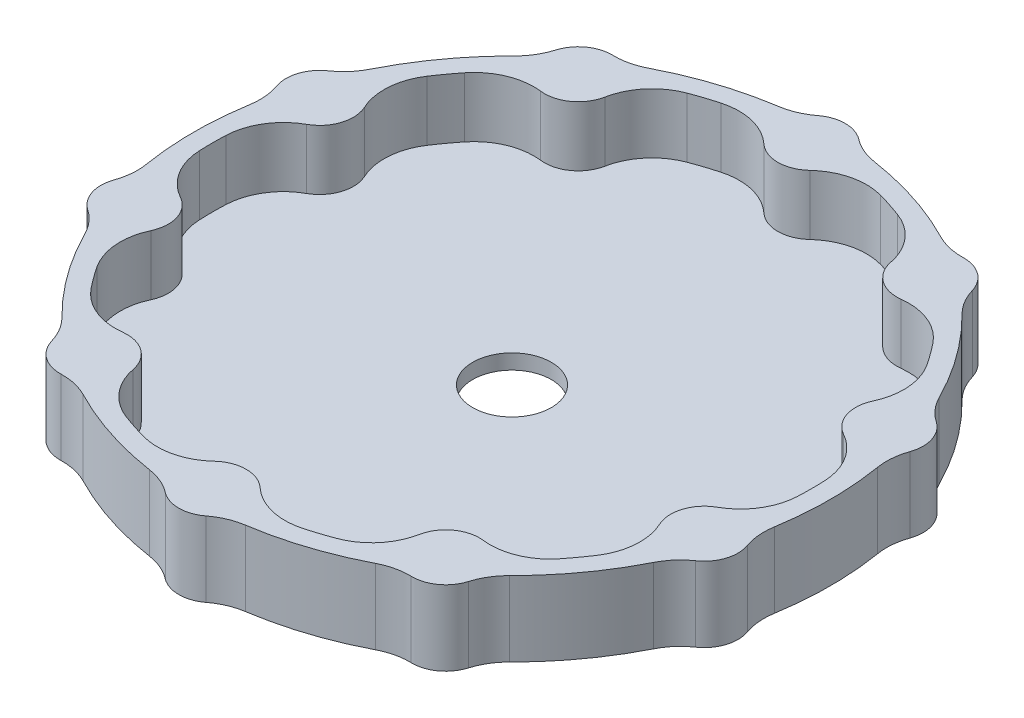
from build123d import *

# Parameters (mm, degrees)
SKETCH1_R                = 42.5
BOSS_EXTRUDE1_DEPTH      = 2
SKETCH2_R                = 4.5
BOSS_EXTRUDE2_DEPTH      = 10
SKETCH4_R                = 5.25
CUT_EXTRUDE1_DEPTH       = 3
SKETCH3_R                = 42.5
SKETCH3_R_2              = 40
BOSS_EXTRUDE4_DEPTH      = 8
FILLET1_R                = 8
CIRPATTERN2_COUNT        = 10
FILLET1_OF_CIRPATTERN2_R = 8


with BuildPart() as part:
    # Sketch1 → Boss-Extrude1 (new body)
    with BuildSketch(Plane(origin=(0, 0, 0), x_dir=(1, 0, 0), z_dir=(0, 1, 0))):
        Circle(SKETCH1_R)
    extrude(amount=BOSS_EXTRUDE1_DEPTH)

    # Sketch2 → Boss-Extrude2 (add)
    with BuildSketch(Plane(origin=(0, 0, 0), x_dir=(1, 0, 0), z_dir=(0, 1, 0))):
        with Locations((0, 40)):
            Circle(SKETCH2_R)
    boss_extrude2 = extrude(amount=BOSS_EXTRUDE2_DEPTH)

    # Sketch4 → Cut-Extrude1 (cut, through all)
    with BuildSketch(Plane(origin=(0, 2, 0), x_dir=(1, 0, 0), z_dir=(0, 1, 0))):
        Circle(SKETCH4_R)
    extrude(amount=-CUT_EXTRUDE1_DEPTH, mode=Mode.SUBTRACT)

    # Sketch3 → Boss-Extrude4 (add)
    with BuildSketch(Plane(origin=(0, 2, 0), x_dir=(1, 0, 0), z_dir=(0, 1, 0))):
        Circle(SKETCH3_R)
        Circle(SKETCH3_R_2, mode=Mode.SUBTRACT)
    extrude(amount=BOSS_EXTRUDE4_DEPTH)

    # Fillet1
    fillet1_edges = [part.edges().sort_by_distance(p)[0] for p in [
        (-4.492875219, 6, -39.746875),
        (4.492875219, 6, -39.746875),
        (3.852839862, 5, -42.325),
        (-3.852839862, 5, -42.325),
    ]]
    fillet(fillet1_edges, radius=FILLET1_R)

    # CirPattern2: Boss-Extrude2 ×10 about axis
    cirpattern2_axis = Axis((0, 0, 0), (0, 1, 0))
    for i in range(1, CIRPATTERN2_COUNT):
        add(boss_extrude2.rotate(cirpattern2_axis, i * 360 / CIRPATTERN2_COUNT))

    # Fillet1 of CirPattern2
    fillet1_of_cirpattern2_edges = [part.edges().sort_by_distance(p)[0] for p in [
        (-26.997439356, 6, -29.515051554),
        (-19.727814544, 6, -34.796743142),
        (-21.760997879, 5, -36.506286737),
        (-27.995023728, 5, -31.977001837),
        (-39.189899267, 6, -8.009481594),
        (-36.413149675, 6, -16.555438102),
        (-39.062874058, 5, -16.743412744),
        (-41.444060046, 5, -9.41487583),
        (-36.413149675, 6, 16.555438102),
        (-39.189899267, 6, 8.009481594),
        (-41.444060046, 5, 9.41487583),
        (-39.062874058, 5, 16.743412744),
        (-19.727814544, 6, 34.796743142),
        (-26.997439356, 6, 29.515051554),
        (-27.995023728, 5, 31.977001837),
        (-21.760997879, 5, 36.506286737),
        (4.492875219, 6, 39.746875),
        (-4.492875219, 6, 39.746875),
        (-3.852839862, 5, 42.325),
        (3.852839862, 5, 42.325),
        (26.997439356, 6, 29.515051554),
        (19.727814544, 6, 34.796743142),
        (21.760997879, 5, 36.506286737),
        (27.995023728, 5, 31.977001837),
        (39.189899267, 6, 8.009481594),
        (36.413149675, 6, 16.555438102),
        (39.062874058, 5, 16.743412744),
        (41.444060046, 5, 9.41487583),
        (36.413149675, 6, -16.555438102),
        (39.189899267, 6, -8.009481594),
        (41.444060046, 5, -9.41487583),
        (39.062874058, 5, -16.743412744),
        (19.727814544, 6, -34.796743142),
        (26.997439356, 6, -29.515051554),
        (27.995023728, 5, -31.977001837),
        (21.760997879, 5, -36.506286737),
    ]]
    fillet(fillet1_of_cirpattern2_edges, radius=FILLET1_OF_CIRPATTERN2_R)


solid = part.part
